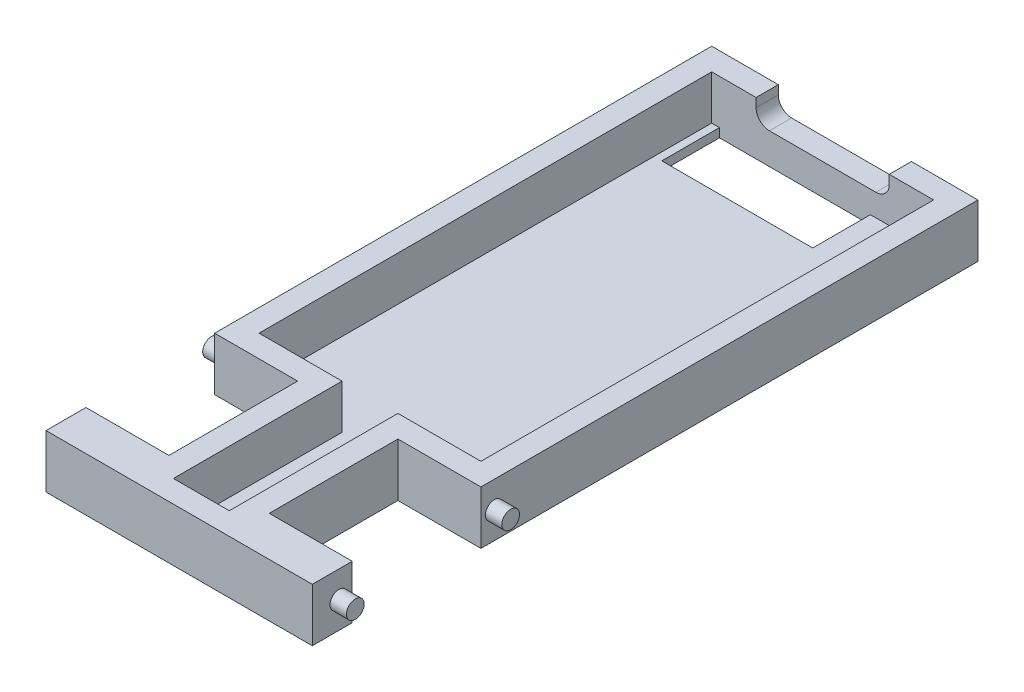
from build123d import *

# Parameters (mm, degrees)
SKETCH1_W               = 60
SKETCH1_H               = 150
SKETCH1_W_2             = 50
SKETCH1_H_2             = 140
BOSS_EXTRUDE1_DEPTH     = 10
SKETCH1_2_W             = 60
SKETCH1_2_H             = 150
SKETCH1_2_W_2           = 50
SKETCH1_2_H_2           = 140
SKETCH1_2_W_3           = 12.5
SKETCH1_2_H_3           = 22.5
BOSS_EXTRUDE2_DEPTH     = 2
SKETCH2_W               = 29
SKETCH2_H               = 12
CUT_EXTRUDE1_DEPTH      = 18.7
SKETCH2_3_R             = 2
BOSS_EXTRUDE3_DEPTH     = 3.7
BOSS_EXTRUDE4_DEPTH     = 10
SKETCH4_W               = 34
SKETCH4_H               = 13
CUT_EXTRUDE2_DEPTH      = 164.406517618
CUT_EXTRUDE2_DEPTH_BACK = 164.406517618
CUT_EXTRUDE3_REACH      = 165.272
SKETCH5_W               = 30
SKETCH5_H               = 5
FILLET1_R               = 3


with BuildPart() as part:
    # Sketch1 → Boss-Extrude1 (new body)
    with BuildSketch(Plane(origin=(0, 0, 0), x_dir=(1, 0, 0), z_dir=(0, 1, 0))):
        with Locations((30, -75)):
            Rectangle(SKETCH1_W, SKETCH1_H)
        with Locations((30, -75)):
            Rectangle(SKETCH1_W_2, SKETCH1_H_2, mode=Mode.SUBTRACT)
    extrude(amount=BOSS_EXTRUDE1_DEPTH)

    # Sketch1_2 → Boss-Extrude2 (add)
    with BuildSketch(Plane(origin=(0, 0, 0), x_dir=(1, 0, 0), z_dir=(0, 1, 0))):
        with Locations((30, -75)):
            Rectangle(SKETCH1_2_W, SKETCH1_2_H)
        with Locations((30, -75)):
            Rectangle(SKETCH1_2_W_2, SKETCH1_2_H_2, mode=Mode.SUBTRACT)
        with Locations((30, -75)):
            Rectangle(SKETCH1_2_W_2, SKETCH1_2_H_2)
        with Locations((30, -34.617801795)):
            Rectangle(SKETCH1_2_W_3, SKETCH1_2_H_3)
    extrude(amount=-BOSS_EXTRUDE2_DEPTH)

    # Sketch2 → Cut-Extrude1 (cut)
    with BuildSketch(Plane.ZY):
        with Locations((126.5, 4)):
            Rectangle(SKETCH2_W, SKETCH2_H)
    cut_extrude1 = extrude(amount=-CUT_EXTRUDE1_DEPTH, mode=Mode.SUBTRACT)

    # Sketch2_3 → Boss-Extrude3 (add)
    with BuildSketch(Plane.ZY):
        with Locations(Location((109, 4, 0), (0, 0, 180))):
            Circle(SKETCH2_3_R)
        with Locations(Location((144, 4, 0), (0, 0, 180))):
            Circle(SKETCH2_3_R)
    boss_extrude3 = extrude(amount=BOSS_EXTRUDE3_DEPTH)

    # Mirror1: Cut-Extrude1, Boss-Extrude3 across plane
    add(cut_extrude1.mirror(Plane.ZY.offset(-30)), mode=Mode.SUBTRACT)
    add(boss_extrude3.mirror(Plane.ZY.offset(-30)))

    # Sketch3 → Boss-Extrude4 (add)
    with BuildSketch(Plane(origin=(0, 0, 0), x_dir=(1, 0, 0), z_dir=(0, 1, 0))):
        Polygon((23.7, -107), (5, -107), (5, -112), (18.7, -112), (18.7, -141), (5, -141), (5, -145), (23.7, -145), align=None)
        Polygon((36.3, -107), (36.3, -145), (55, -145), (55, -141), (41.3, -141), (41.3, -112), (55, -112), (55, -107), align=None)
    extrude(amount=BOSS_EXTRUDE4_DEPTH)

    # Sketch4 → Cut-Extrude2 (cut, two sides)
    with BuildSketch(Plane.XZ.offset(2)) as cut_extrude2_sk:
        with Locations((23.75, 11.5)):
            Rectangle(SKETCH4_W, SKETCH4_H)
    extrude(amount=CUT_EXTRUDE2_DEPTH, mode=Mode.SUBTRACT)
    extrude(cut_extrude2_sk.sketch, amount=-CUT_EXTRUDE2_DEPTH_BACK, mode=Mode.SUBTRACT)

    # Sketch5 → Cut-Extrude3 (cut, up to next)
    with BuildSketch(Plane(origin=(0, 0, 0), x_dir=(-1, 0, 0), z_dir=(0, 0, -1)), mode=Mode.PRIVATE) as cut_extrude3_sk1:
        with Locations((-30, 7.5)):
            Rectangle(SKETCH5_W, SKETCH5_H)
    cut_extrude3_tool1 = extrude(cut_extrude3_sk1.sketch, amount=-CUT_EXTRUDE3_REACH, mode=Mode.PRIVATE) & part.part
    add(cut_extrude3_tool1.solids().sort_by_distance((30, 7.5, 0))[0], mode=Mode.SUBTRACT)

    # Fillet1
    fillet1_edges = [part.edges().sort_by_distance(p)[0] for p in [
        (45, 5, 2.5),
        (15, 5, 2.5),
    ]]
    fillet(fillet1_edges, radius=FILLET1_R)


solid = part.part
